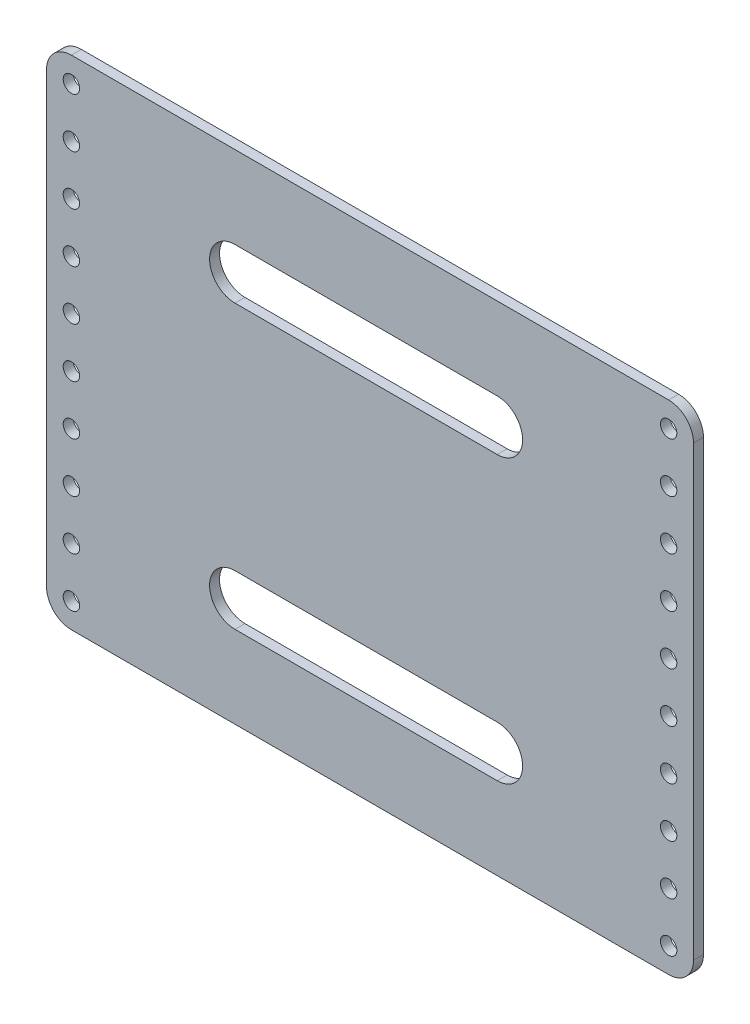
from build123d import *

# Parameters (mm, degrees)
SKETCH_1_W                  = 130
SKETCH_1_H                  = 100
EXTRUDE_1_DEPTH             = 2
FILLET_1_R                  = 5
SKETCH_2_R                  = 1.65
CUT_EXTRUDE_1_DEPTH         = 2
PATTERN_LINEAR_1_COUNT      = 2
PATTERN_LINEAR_1_PITCH      = 120
PATTERN_LINEAR_1_COUNT_DIR2 = 10
PATTERN_LINEAR_1_PITCH_DIR2 = 10
CUT_EXTRUDE_2_DEPTH         = 2


with BuildPart() as part:
    # 草图1 → 凸台-拉伸1 (new body)
    with BuildSketch(Plane.XY):
        with Locations((65, 50)):
            Rectangle(SKETCH_1_W, SKETCH_1_H)
    extrude(amount=EXTRUDE_1_DEPTH)

    # 圆角1
    fillet_1_edges = [part.edges().sort_by_distance(p)[0] for p in [
        (0, 100, 1),
        (130, 100, 1),
        (130, 0, 1),
        (0, 0, 1),
    ]]
    fillet(fillet_1_edges, radius=FILLET_1_R)

    # 草图2 → 切除-拉伸1 (cut)
    with BuildSketch(Plane.XY.offset(2)):
        with Locations((5, 95)):
            Circle(SKETCH_2_R)
    cut_extrude_1 = extrude(amount=-CUT_EXTRUDE_1_DEPTH, mode=Mode.SUBTRACT)

    # 阵列(线性)1: Cut-Extrude 1 2 × 10
    with Locations(*[(i * PATTERN_LINEAR_1_PITCH, -j * PATTERN_LINEAR_1_PITCH_DIR2, 0) for i in range(PATTERN_LINEAR_1_COUNT) for j in range(PATTERN_LINEAR_1_COUNT_DIR2) if (i, j) != (0, 0)]):
        add(cut_extrude_1, mode=Mode.SUBTRACT)

    # 草图3 → 切除-拉伸2 (cut)
    with BuildSketch(Plane.XY.offset(2)):
        with BuildLine():
            Line((37.866154951, 73.279191598), (90.557089201, 73.279191598))
            ThreePointArc((90.557089201, 73.279191598), (95.658146272, 78.380248669), (90.557089201, 83.48130574))
            Line((90.557089201, 83.48130574), (37.866154951, 83.48130574))
            ThreePointArc((37.866154951, 83.48130574), (32.76509788, 78.380248669), (37.866154951, 73.279191598))
        make_face()
        with BuildLine():
            ThreePointArc((90.557089201, 26.720808402), (95.658146272, 21.619751331), (90.557089201, 16.51869426))
            Line((90.557089201, 16.51869426), (37.866154951, 16.51869426))
            ThreePointArc((37.866154951, 16.51869426), (32.76509788, 21.619751331), (37.866154951, 26.720808402))
            Line((37.866154951, 26.720808402), (90.557089201, 26.720808402))
        make_face()
    extrude(amount=-CUT_EXTRUDE_2_DEPTH, mode=Mode.SUBTRACT)


solid = part.part
